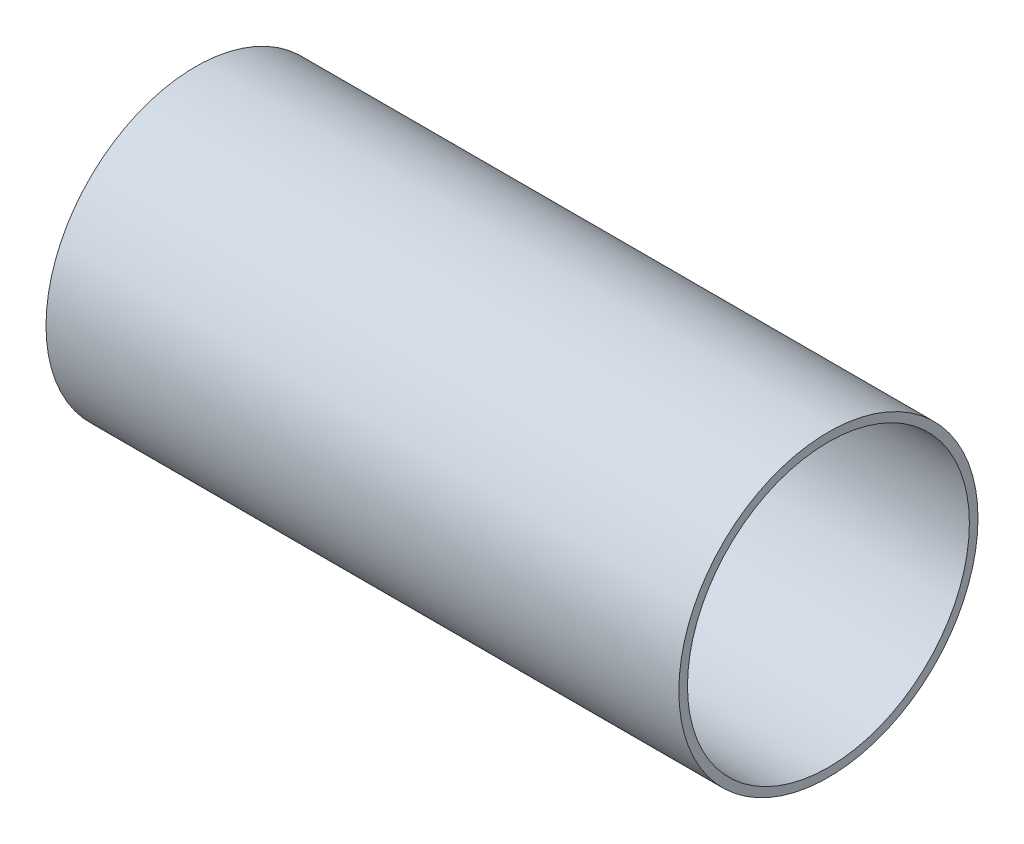
from build123d import *

# Parameters (mm, degrees)
SKETCH1_R           = 52
SKETCH1_R_2         = 49
BOSS_EXTRUDE1_DEPTH = 220


with BuildPart() as part:
    # Sketch1 → Boss-Extrude1 (new body)
    with BuildSketch(Plane(origin=(0, 0, 0), x_dir=(0, 0, -1), z_dir=(1, 0, 0))):
        Circle(SKETCH1_R)
        Circle(SKETCH1_R_2, mode=Mode.SUBTRACT)
    extrude(amount=BOSS_EXTRUDE1_DEPTH)


solid = part.part
